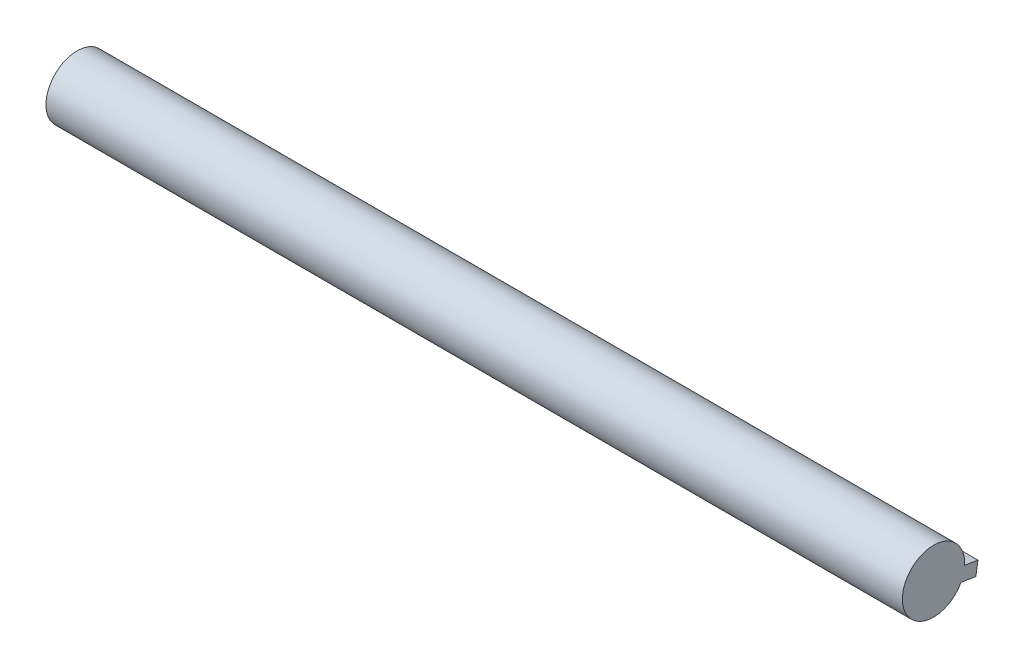
from build123d import *

# Parameters (mm, degrees)
SKETCH1_R             = 7
BOSS_EXTRUDE1_DEPTH   = 192.48
SKETCH2_W             = 15
SKETCH2_H             = 3
BOSS_EXTRUDE2_DEPTH   = 3
SKETCH2_W_2           = 16.730233444
SKETCH2_H_2           = 2.564845708
BOSS_EXTRUDE2_2_DEPTH = 3
SKETCH3_W             = 16.730233444
SKETCH3_H             = 2.564845708
BOSS_EXTRUDE3_DEPTH   = 10
SKETCH4_W             = 15
SKETCH4_H             = 3
BOSS_EXTRUDE4_DEPTH   = 10


with BuildPart() as part:
    # Sketch1 → Boss-Extrude1 (new body)
    with BuildSketch(Plane(origin=(0, 0, 0), x_dir=(0, 0, -1), z_dir=(1, 0, 0))):
        Circle(SKETCH1_R)
    extrude(amount=BOSS_EXTRUDE1_DEPTH)



with BuildPart() as body_2:
    # Sketch2 → Boss-Extrude2 (new body)
    with BuildSketch(Plane(origin=(0, -1.130854734, -6.908050924), x_dir=(1, 0, 0), z_dir=(0, -0.161550676, -0.986864418))):
        with Locations((184.98, 0.763298878)):
            Rectangle(SKETCH2_W, SKETCH2_H)
    extrude(amount=BOSS_EXTRUDE2_DEPTH)


with BuildPart() as body_3:
    # Sketch2 → Boss-Extrude2 2 (new body)
    with BuildSketch(Plane(origin=(0, -1.130854734, -6.908050924), x_dir=(1, 0, 0), z_dir=(0, -0.161550676, -0.986864418))):
        with Locations((8.365116722, 0.545721732)):
            Rectangle(SKETCH2_W_2, SKETCH2_H_2)
    extrude(amount=BOSS_EXTRUDE2_2_DEPTH)


with BuildPart() as part_1:
    add(part.part)

    add(body_3.part)  # Boss-Extrude3 merges body 3
    # Sketch3 → Boss-Extrude3 (add)
    with BuildSketch(Plane(origin=(0, -1.130854734, -6.908050924), x_dir=(1, 0, 0), z_dir=(0, 0.161550676, 0.986864418))):
        with Locations((8.365116722, -0.545721732)):
            Rectangle(SKETCH3_W, SKETCH3_H)
    extrude(amount=BOSS_EXTRUDE3_DEPTH)


    add(body_2.part)  # Boss-Extrude4 merges body 2
    # Sketch4 → Boss-Extrude4 (add)
    with BuildSketch(Plane(origin=(0, -1.130854734, -6.908050924), x_dir=(1, 0, 0), z_dir=(0, 0.161550676, 0.986864418))):
        with Locations((184.98, -0.763298878)):
            Rectangle(SKETCH4_W, SKETCH4_H)
    extrude(amount=BOSS_EXTRUDE4_DEPTH)


solid = part_1.part
